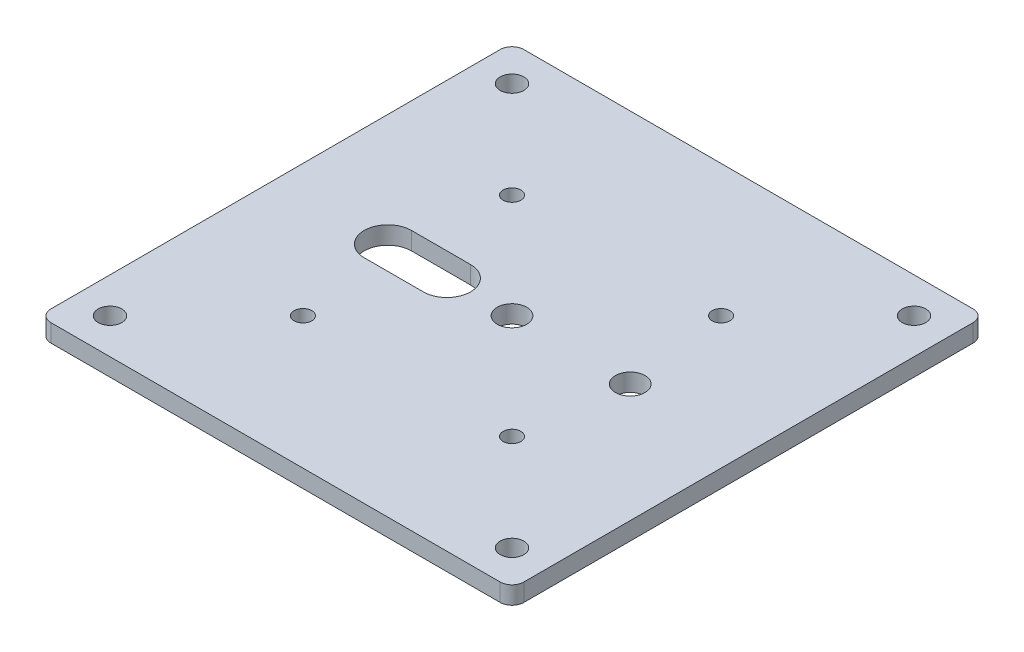
from build123d import *

# Parameters (mm, degrees)
ESQUISSE1_W      = 80
ESQUISSE1_H      = 80
ESQUISSE1_R      = 2.5
ESQUISSE1_R_2    = 1.5
ESQUISSE1_R_3    = 2
EXTRUSION1_DEPTH = 3
CONG_1_R         = 2


with BuildPart() as part:
    # Esquisse1 → Extrusion1 (new body)
    with BuildSketch(Plane(origin=(0, 0, 0), x_dir=(1, 0, 0), z_dir=(0, 1, 0))):
        with Locations((40, 40)):
            Rectangle(ESQUISSE1_W, ESQUISSE1_H)
        with Locations((40, 40)):
            Circle(ESQUISSE1_R, mode=Mode.SUBTRACT)
        with Locations((60, 40)):
            Circle(ESQUISSE1_R, mode=Mode.SUBTRACT)
        with Locations((57.67766953, 57.67766953)):
            Circle(ESQUISSE1_R_2, mode=Mode.SUBTRACT)
        with Locations((22.32233047, 22.32233047)):
            Circle(ESQUISSE1_R_2, mode=Mode.SUBTRACT)
        with Locations((22.32233047, 57.67766953)):
            Circle(ESQUISSE1_R_2, mode=Mode.SUBTRACT)
        with Locations((57.67766953, 22.32233047)):
            Circle(ESQUISSE1_R_2, mode=Mode.SUBTRACT)
        with Locations((6, 74)):
            Circle(ESQUISSE1_R_3, mode=Mode.SUBTRACT)
        with Locations((74, 74)):
            Circle(ESQUISSE1_R_3, mode=Mode.SUBTRACT)
        with Locations((74, 6)):
            Circle(ESQUISSE1_R_3, mode=Mode.SUBTRACT)
        with Locations((6, 6)):
            Circle(ESQUISSE1_R_3, mode=Mode.SUBTRACT)
        with BuildLine():
            Line((19, 44), (29, 44))
            ThreePointArc((29, 44), (31.828427125, 42.828427125), (33, 40))
            ThreePointArc((33, 40), (31.828427125, 37.171572875), (29, 36))
            Line((29, 36), (19, 36))
            ThreePointArc((19, 36), (16.171572875, 37.171572875), (15, 40))
            ThreePointArc((15, 40), (16.171572875, 42.828427125), (19, 44))
        make_face(mode=Mode.SUBTRACT)
    extrude(amount=EXTRUSION1_DEPTH)

    # Congé1
    cong_1_edges = [part.edges().sort_by_distance(p)[0] for p in [
        (0, 1.5, -80),
        (80, 1.5, -80),
        (80, 1.5, 0),
        (0, 1.5, 0),
    ]]
    fillet(cong_1_edges, radius=CONG_1_R)


solid = part.part
